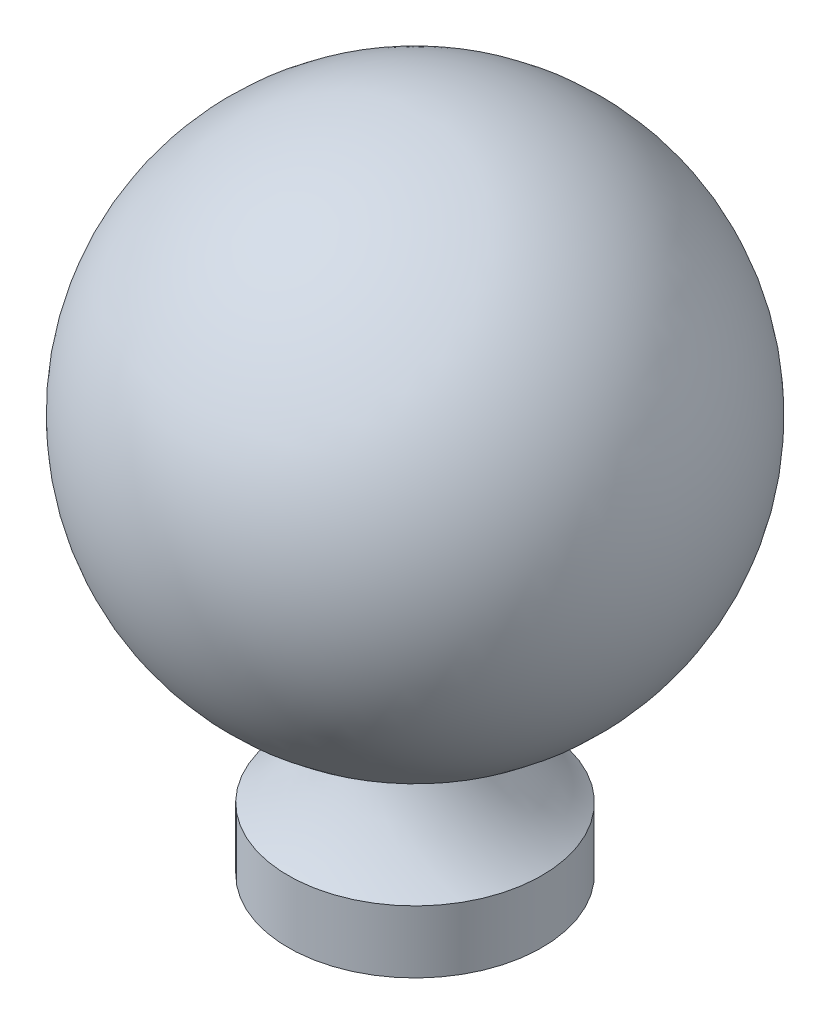
from build123d import *


with BuildPart() as part:
    # Sketch1 → Revolve1 (revolve)
    with BuildSketch(Plane.XY):
        with BuildLine():
            Line((0, 0), (2.795, 0))
            Line((2.795, 0), (2.795, 1.375089342))
            ThreePointArc((2.795, 1.375089342), (2.028795721, 2.180119301), (1.528273182, 3.172399211))
            ThreePointArc((1.528273182, 3.172399211), (1.531555951, 3.211573609), (1.562144546, 3.236266684))
            ThreePointArc((1.562144546, 3.236266684), (5.695676719, 9.558521855), (0, 14.52))
            Line((0, 14.52), (0, 0))
        make_face()
    revolve(axis=Axis((0, 0, 0), (0, 1, 0)))


solid = part.part
